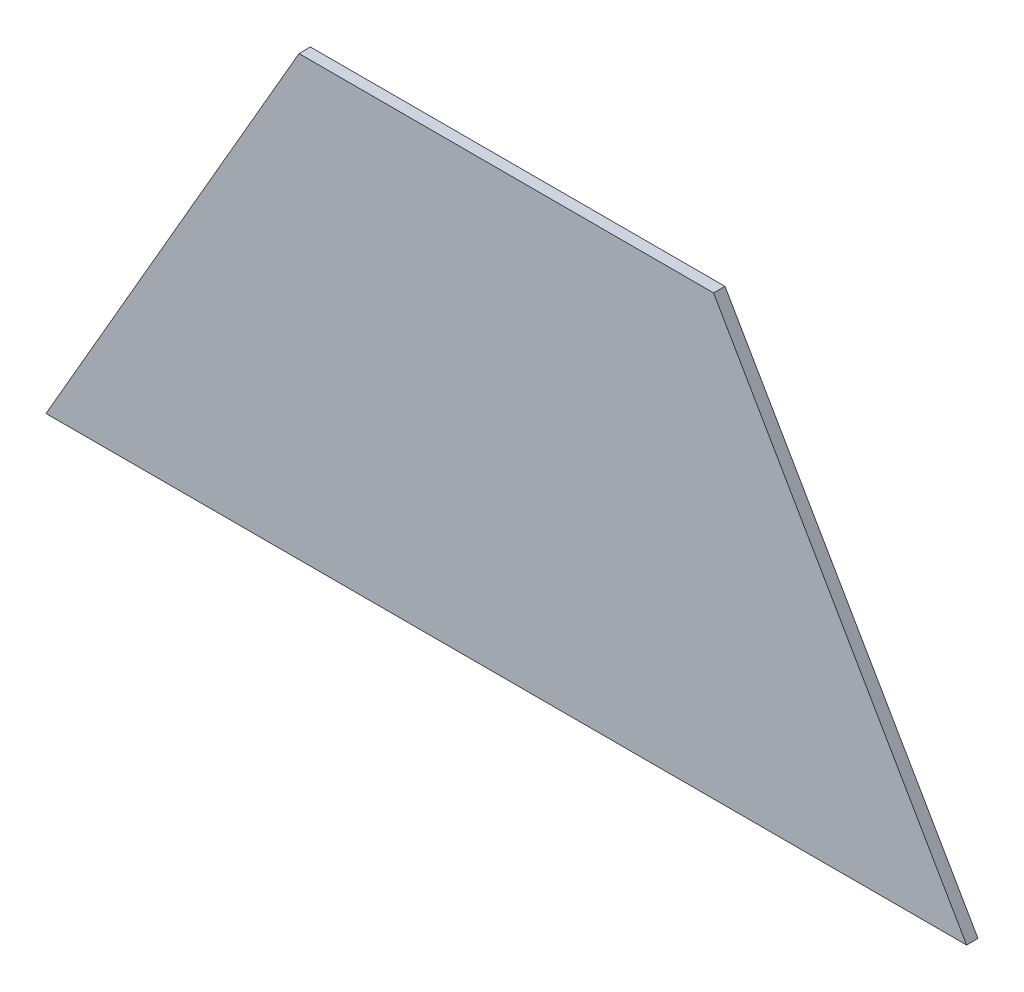
from build123d import *

# Parameters (mm, degrees)
BOSS_EXTRUDE1_DEPTH = 11.90625


with BuildPart() as part:
    # Sketch1 → Boss-Extrude1 (new body)
    with BuildSketch(Plane.XY):
        Polygon((-480.203491154, -831.736844651), (480.203491154, -831.736844651), (216.238948081, -374.536844651), (-216.238948081, -374.536844651), align=None)
    extrude(amount=-BOSS_EXTRUDE1_DEPTH)


solid = part.part
